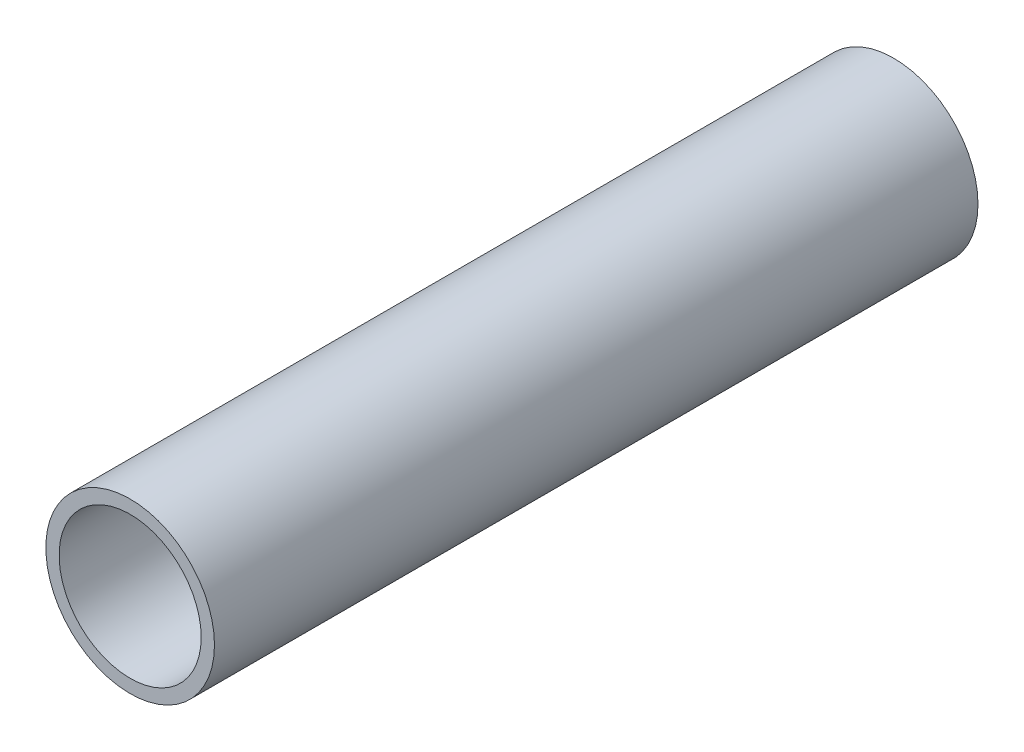
from build123d import *

# Parameters (mm, degrees)
SKETCH1_R           = 12.7
SKETCH1_R_2         = 10.7
BOSS_EXTRUDE1_DEPTH = 115


with BuildPart() as part:
    # Sketch1 → Boss-Extrude1 (new body)
    with BuildSketch(Plane.XY):
        Circle(SKETCH1_R)
        Circle(SKETCH1_R_2, mode=Mode.SUBTRACT)
    extrude(amount=BOSS_EXTRUDE1_DEPTH)


solid = part.part
